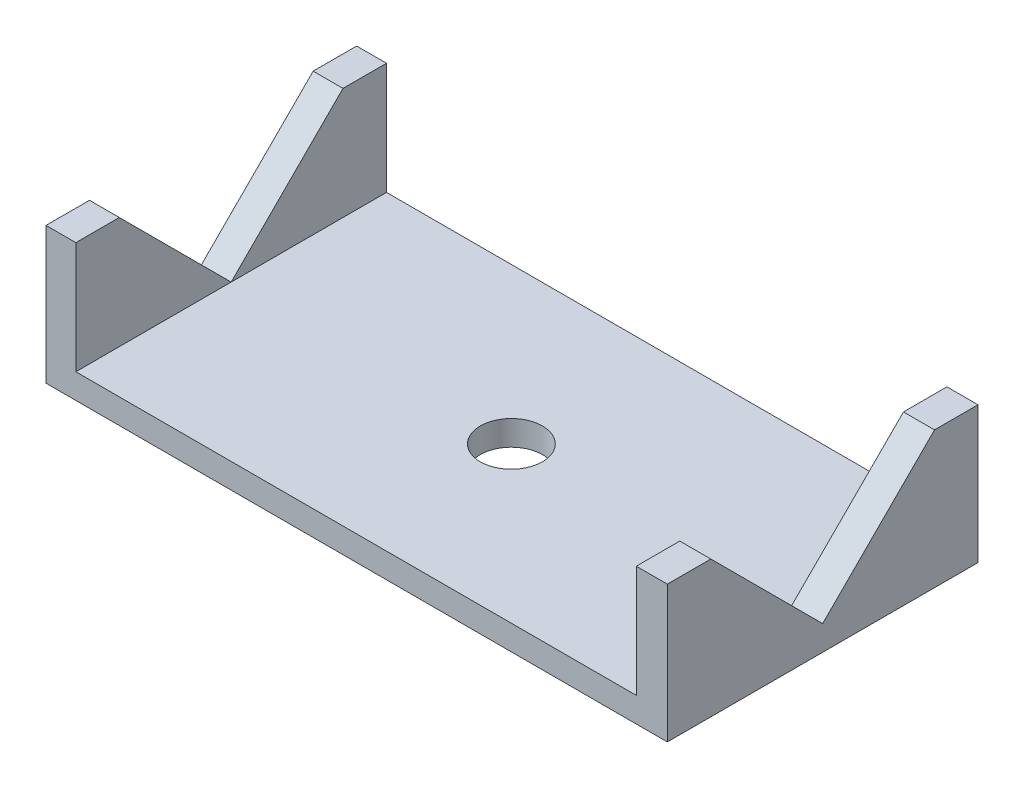
from build123d import *

# Parameters (mm, degrees)
SKETCH1_W           = 50
SKETCH1_H           = 25
BOSS_EXTRUDE1_DEPTH = 2
SKETCH2_W           = 2.4
SKETCH2_H           = 25
BOSS_EXTRUDE2_DEPTH = 9
CUT_EXTRUDE1_DEPTH  = 9
SKETCH4_W           = 2.5
SKETCH4_H           = 25
BOSS_EXTRUDE3_DEPTH = 9
CUT_EXTRUDE2_DEPTH  = 9
SKETCH6_R           = 2.5
CUT_EXTRUDE4_DEPTH  = 3


with BuildPart() as part:
    # Sketch1 → Boss-Extrude1 (new body)
    with BuildSketch(Plane(origin=(0, 0, 0), x_dir=(1, 0, 0), z_dir=(0, 1, 0))):
        Rectangle(SKETCH1_W, SKETCH1_H)
    extrude(amount=BOSS_EXTRUDE1_DEPTH)

    # Sketch2 → Boss-Extrude2 (add)
    with BuildSketch(Plane(origin=(0, 2, 0), x_dir=(1, 0, 0), z_dir=(0, 1, 0))):
        with Locations((-23.8, 0)):
            Rectangle(SKETCH2_W, SKETCH2_H)
    extrude(amount=BOSS_EXTRUDE2_DEPTH)

    # Sketch3 → Cut-Extrude1 (cut)
    with BuildSketch(Plane(origin=(-22.6, 0, 0), x_dir=(0, 0, -1), z_dir=(1, 0, 0))):
        Polygon((-9, 11), (0, 2), (9, 11), align=None)
    extrude(amount=-CUT_EXTRUDE1_DEPTH, mode=Mode.SUBTRACT)

    # Sketch4 → Boss-Extrude3 (add)
    with BuildSketch(Plane(origin=(0, 2, 0), x_dir=(1, 0, 0), z_dir=(0, 1, 0))):
        with Locations((23.75, 0)):
            Rectangle(SKETCH4_W, SKETCH4_H)
    extrude(amount=BOSS_EXTRUDE3_DEPTH)

    # Sketch5 → Cut-Extrude2 (cut)
    with BuildSketch(Plane.ZY.offset(-22.5)):
        Polygon((0, 2), (-9, 11), (9, 11), align=None)
    extrude(amount=-CUT_EXTRUDE2_DEPTH, mode=Mode.SUBTRACT)

    # Sketch6 → Cut-Extrude4 (cut, through all)
    with BuildSketch(Plane(origin=(0, 2, 0), x_dir=(1, 0, 0), z_dir=(0, 1, 0))):
        with Locations((-0.05, 0)):
            Circle(SKETCH6_R)
    extrude(amount=-CUT_EXTRUDE4_DEPTH, mode=Mode.SUBTRACT)


solid = part.part
